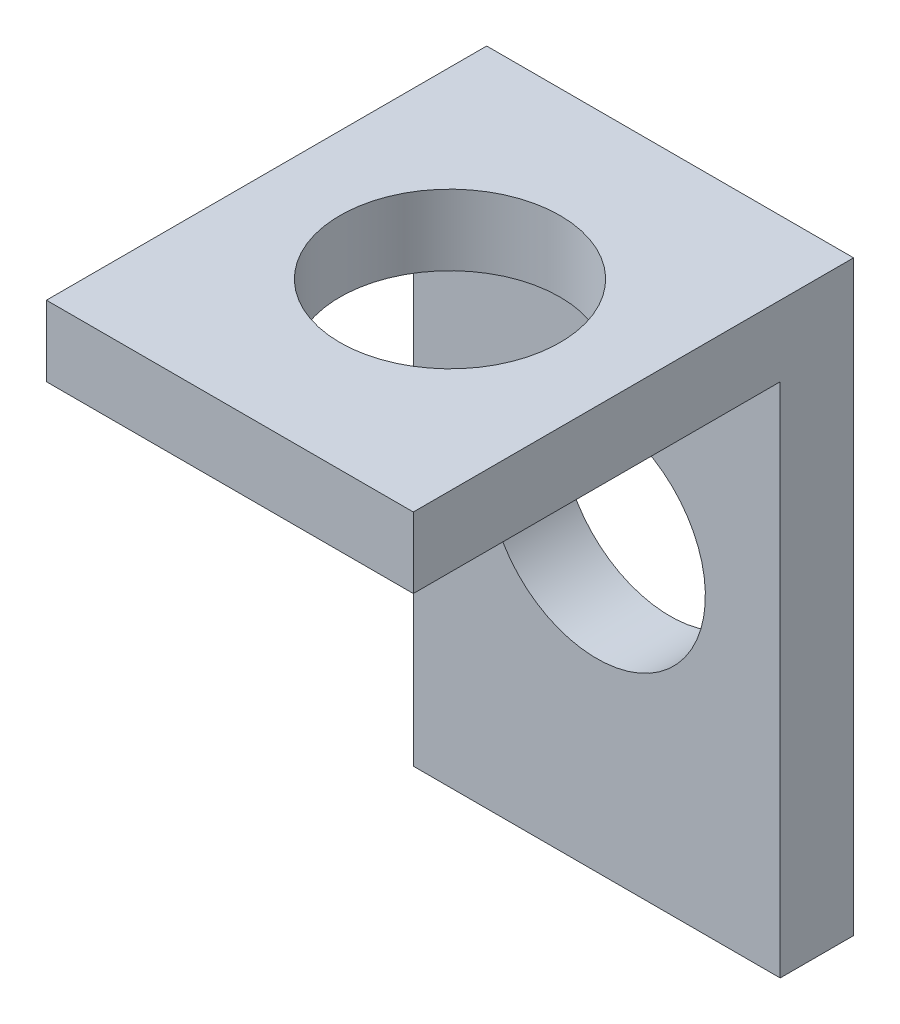
from build123d import *

# Parameters (mm, degrees)
BOSS_EXTRUDE1_DEPTH = 6.35
SKETCH6_R           = 3.760114337
CUT_EXTRUDE3_DEPTH  = 12.7
SKETCH8_R           = 3.81
CUT_EXTRUDE4_DEPTH  = 2.54


with BuildPart() as part:
    # Sketch1 → Boss-Extrude1 (new body, symmetric)
    with BuildSketch(Plane(origin=(0, 0, 0), x_dir=(0, 0, -1), z_dir=(1, 0, 0))):
        Polygon((0, 0), (0, -17.874529582), (2.54, -17.874529582), (2.54, 2.445470418), (-12.7, 2.445470418), (-12.7, 0), align=None)
    extrude(amount=BOSS_EXTRUDE1_DEPTH, both=True)

    # Sketch6 → Cut-Extrude3 (cut)
    with BuildSketch(Plane(origin=(0, 0, -2.54), x_dir=(-1, 0, 0), z_dir=(0, 0, -1))):
        with Locations((0, -7.714529582)):
            Circle(SKETCH6_R)
    extrude(amount=-CUT_EXTRUDE3_DEPTH, mode=Mode.SUBTRACT)

    # Sketch8 → Cut-Extrude4 (cut)
    with BuildSketch(Plane(origin=(0, 2.445470418, 0), x_dir=(1, 0, 0), z_dir=(0, 1, 0))):
        with Locations((0, -5.08)):
            Circle(SKETCH8_R)
    extrude(amount=-CUT_EXTRUDE4_DEPTH, mode=Mode.SUBTRACT)


solid = part.part
